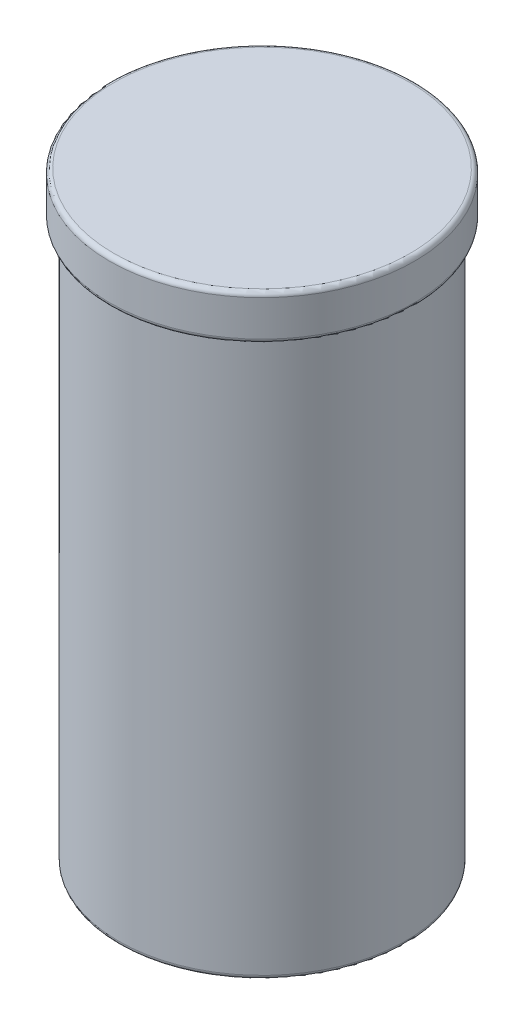
from build123d import *

# Parameters (mm, degrees)
SKETCH1_R           = 16
BOSS_EXTRUDE1_DEPTH = 67.12
BOSS_EXTRUDE2_START = -67.12
SKETCH2_R           = 17
SKETCH2_R_2         = 16
BOSS_EXTRUDE2_DEPTH = 5
FILLET1_R           = 0.5


with BuildPart() as part:
    # Sketch1 → Boss-Extrude1 (new body)
    with BuildSketch(Plane(origin=(0, 0, 0), x_dir=(1, 0, 0), z_dir=(0, 1, 0))):
        Circle(SKETCH1_R)
    extrude(amount=BOSS_EXTRUDE1_DEPTH)

    # Sketch2 → Boss-Extrude2 (add)
    with BuildSketch(Plane.XZ.offset(BOSS_EXTRUDE2_START)):
        Circle(SKETCH2_R)
        Circle(SKETCH2_R_2, mode=Mode.SUBTRACT)
    extrude(amount=BOSS_EXTRUDE2_DEPTH)

    # Fillet1
    fillet1_edges = [part.edges().sort_by_distance(p)[0] for p in [
        (-16, 0, 0),
        (-17, 62.12, 0),
        (-17, 67.12, 0),
    ]]
    fillet(fillet1_edges, radius=FILLET1_R)


solid = part.part
